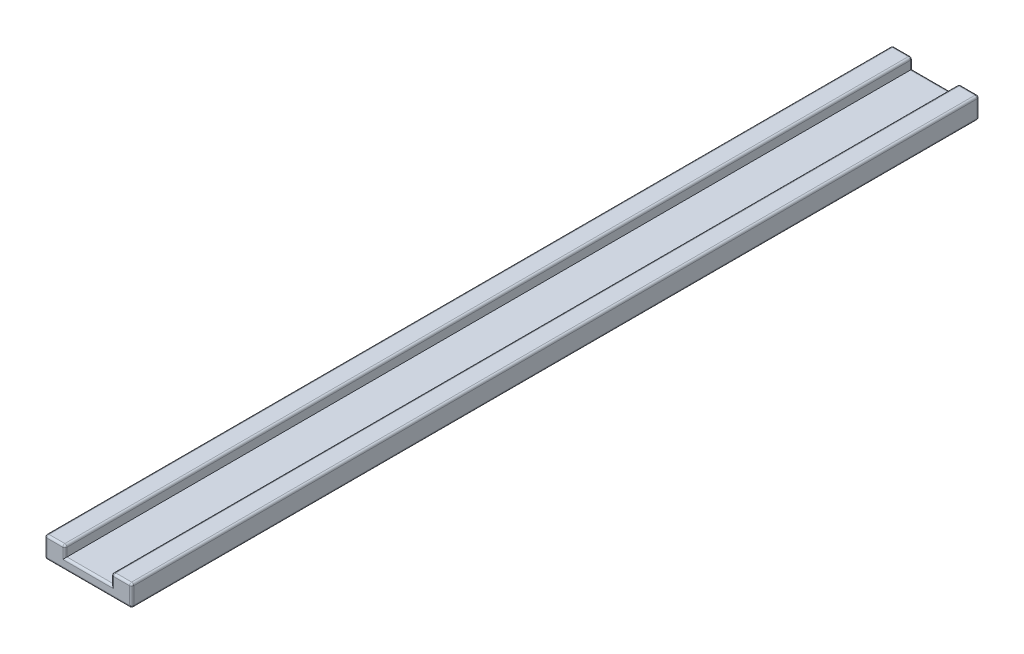
from build123d import *

# Parameters (mm, degrees)
BOSS_EXTRUDE1_DEPTH = 400
FILLET1_R           = 1
FILLET2_R           = 1


with BuildPart() as part:
    # Sketch1 → Boss-Extrude1 (new body)
    with BuildSketch(Plane.XY):
        Polygon((-11, 5), (-11, 0), (11, 0), (11, 5), (20.5, 5), (20.5, -5), (-20.5, -5), (-20.5, 5), align=None)
    extrude(amount=BOSS_EXTRUDE1_DEPTH)

    # Fillet1
    fillet1_edges = [part.edges().sort_by_distance(p)[0] for p in [
        (20.5, 5, 200),
        (20.5, -5, 200),
        (-20.5, -5, 200),
        (-20.5, 5, 200),
        (-11, 5, 200),
        (11, 5, 200),
    ]]
    fillet(fillet1_edges, radius=FILLET1_R)

    # Fillet2
    fillet2_edges = [part.edges().sort_by_distance(p)[0] for p in [
        (0, 0, 400),
        (-11, 2, 400),
        (11, 2, 0),
        (11, 2, 400),
        (15.75, 5, 0),
        (20.5, 0, 0),
        (0, -5, 0),
        (-20.5, 0, 0),
        (-15.75, 5, 0),
        (20.207106781, 4.707106781, 0),
        (-20.207106781, 4.707106781, 0),
        (-20.207106781, -4.707106781, 0),
        (20.207106781, -4.707106781, 0),
        (-11.292893219, 4.707106781, 0),
        (11.292893219, 4.707106781, 0),
        (15.75, 5, 400),
        (-15.75, 5, 400),
        (-20.5, 0, 400),
        (0, -5, 400),
        (20.5, 0, 400),
        (20.207106781, 4.707106781, 400),
        (-20.207106781, 4.707106781, 400),
        (-20.207106781, -4.707106781, 400),
        (20.207106781, -4.707106781, 400),
        (-11.292893219, 4.707106781, 400),
        (11.292893219, 4.707106781, 400),
        (-11, 2, 0),
        (0, 0, 0),
    ]]
    fillet(fillet2_edges, radius=FILLET2_R)


solid = part.part
